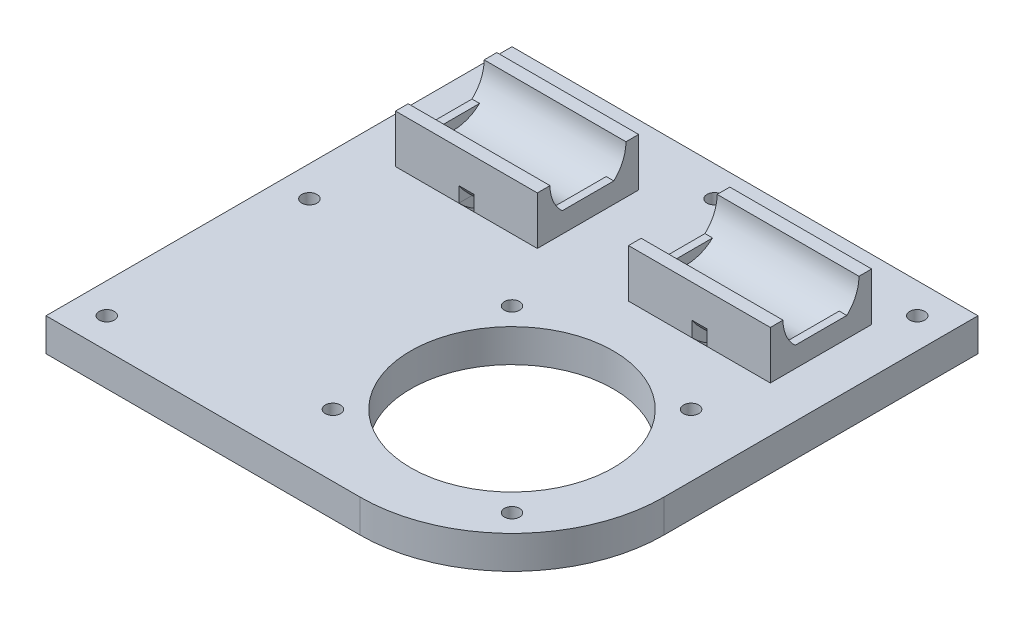
from build123d import *
from build123d.topology import SkipClean

# Parameters (mm, degrees)
EXTRUDE2_DEPTH      = 4
EXTRUDE2_DEPTH_BACK = 2.5
SKETCH7_R           = 20
SKETCH7_R_2         = 1.5
SKETCH8_W           = 28
SKETCH8_H           = 20
EXTRUDE3_DEPTH      = 9.5
EXTRUDE6_DEPTH      = 28
SKETCH15_R          = 7.5
EXTRUDE7_DEPTH      = 25
SKETCH16_W          = 3
SKETCH16_H          = 3
SKETCH8_4_W         = 28
SKETCH8_4_H         = 20
EXTRUDE8_DEPTH      = 9.5
EXTRUDE9_DEPTH      = 28
SKETCH19_R          = 7.5
EXTRUDE10_DEPTH     = 25
SKETCH20_W          = 3
SKETCH20_H          = 3


with BuildPart() as part:
    # Sketch7 → Extrude2 (new, two sides: drawn at the far end of the back side and taken through both)
    with BuildSketch(Plane(origin=(0, 0, 0), x_dir=(1, 0, 0), z_dir=(0, 1, 0)).offset(-EXTRUDE2_DEPTH_BACK)):
        with BuildLine():
            Line((-46, -46), (16, -46))
            ThreePointArc((16, -46), (37.213203436, -37.213203436), (46, -16))
            Line((46, -16), (46, 46))
            Line((46, 46), (-46, 46))
            Line((-46, 46), (-46, -46))
        make_face()
        with Locations((16, -16)):
            Circle(SKETCH7_R, mode=Mode.SUBTRACT)
        with Locations((-1.67766953, 1.67766953)):
            Circle(SKETCH7_R_2, mode=Mode.SUBTRACT)
        with Locations((-40, 40)):
            Circle(SKETCH7_R_2, mode=Mode.SUBTRACT)
        with Locations((-40, -40)):
            Circle(SKETCH7_R_2, mode=Mode.SUBTRACT)
        with Locations((40, 40)):
            Circle(SKETCH7_R_2, mode=Mode.SUBTRACT)
        with Locations((0, 40)):
            Circle(SKETCH7_R_2, mode=Mode.SUBTRACT)
        with Locations((-40, 0)):
            Circle(SKETCH7_R_2, mode=Mode.SUBTRACT)
        with Locations((33.67766953, 1.67766953)):
            Circle(SKETCH7_R_2, mode=Mode.SUBTRACT)
        with Locations((33.67766953, -33.67766953)):
            Circle(SKETCH7_R_2, mode=Mode.SUBTRACT)
        with Locations((-1.67766953, -33.67766953)):
            Circle(SKETCH7_R_2, mode=Mode.SUBTRACT)
    extrude(amount=EXTRUDE2_DEPTH + EXTRUDE2_DEPTH_BACK)


with BuildPart() as body_2:
    # Sketch8 → Extrude3 (new body)
    with BuildSketch(Plane(origin=(0, 4, 0), x_dir=(1, 0, 0), z_dir=(0, 1, 0))):
        with Locations((-23, 24)):
            Rectangle(SKETCH8_W, SKETCH8_H)
    extrude(amount=EXTRUDE3_DEPTH)

    # Sketch10 → Extrude6 (cut)
    with BuildSketch(Plane(origin=(-9, 0, 0), x_dir=(0, 0, -1), z_dir=(1, 0, 0))):
        with BuildLine():
            Line((31.5, 13.5), (24, 13.5))
            Line((24, 13.5), (16.5, 13.5))
            ThreePointArc((16.5, 13.5), (17.126403912, 10.499387259), (18.900980486, 8))
            Line((18.900980486, 8), (29.099019514, 8))
            ThreePointArc((29.099019514, 8), (30.873596088, 10.499387259), (31.5, 13.5))
        make_face()
    extrude(amount=-EXTRUDE6_DEPTH, mode=Mode.SUBTRACT)

    # Sketch15 → Extrude7 (cut)
    with SkipClean():  # the faces are left unmerged after this step: merging them gives an invalid solid
        with BuildSketch(Plane.ZY.offset(35.5)):
            with Locations((-24, 13.5)):
                Circle(SKETCH15_R)
        extrude(amount=-EXTRUDE7_DEPTH, mode=Mode.SUBTRACT)


with BuildPart() as cut_sweep1_tool:
    # Cut-Sweep1: sweep along a path in Sketch17
    with SkipClean():  # the faces are left unmerged after this step: merging them gives an invalid solid
        with BuildLine(Plane(origin=(-23, 0, 0), x_dir=(0, 0, -1), z_dir=(1, 0, 0))) as cut_sweep1_path:
            CenterArc((24, 13.5), 12.806248475, 0, 360)
        # Sketch16 → Cut-Sweep1 (sweep)
        with BuildSketch(Plane.XY.offset(-14)):
            with Locations((-23, 5.5)):
                Rectangle(SKETCH16_W, SKETCH16_H)
        sweep(path=cut_sweep1_path.line)


with BuildPart() as part_1:
    with SkipClean():  # the faces are left unmerged after this step: merging them gives an invalid solid
        add(part.part)

        # Cut-Sweep1: cut by cut_sweep1_tool
        add(cut_sweep1_tool.part, mode=Mode.SUBTRACT)

    # Sketch8_4 → Extrude8 (add)
    with BuildSketch(Plane(origin=(0, 4, 0), x_dir=(1, 0, 0), z_dir=(0, 1, 0))):
        with Locations((23, 24)):
            Rectangle(SKETCH8_4_W, SKETCH8_4_H)
    extrude(amount=EXTRUDE8_DEPTH)

    # Sketch18 → Extrude9 (cut)
    with BuildSketch(Plane(origin=(37, 0, 0), x_dir=(0, 0, -1), z_dir=(1, 0, 0))):
        with BuildLine():
            Line((18.900980486, 8), (29.099019514, 8))
            ThreePointArc((29.099019514, 8), (30.873596088, 10.499387259), (31.5, 13.5))
            Line((31.5, 13.5), (16.5, 13.5))
            ThreePointArc((16.5, 13.5), (17.126403912, 10.499387259), (18.900980486, 8))
        make_face()
    extrude(amount=-EXTRUDE9_DEPTH, mode=Mode.SUBTRACT)

    # Sketch19 → Extrude10 (cut)
    with BuildSketch(Plane(origin=(35.5, 0, 0), x_dir=(0, 0, -1), z_dir=(1, 0, 0))):
        with Locations((24, 13.5)):
            Circle(SKETCH19_R)
    extrude(amount=-EXTRUDE10_DEPTH, mode=Mode.SUBTRACT)

    # Cut-Sweep2: sweep along a path in Sketch21
    with BuildLine(Plane(origin=(23, 0, 0), x_dir=(0, 0, -1), z_dir=(1, 0, 0))) as cut_sweep2_path:
        CenterArc((24, 13.5), 12.806248475, 0, 360)
    # Sketch20 → Cut-Sweep2 (sweep, cut)
    with BuildSketch(Plane.XY.offset(-14)):
        with Locations((23, 5.5)):
            Rectangle(SKETCH20_W, SKETCH20_H)
    sweep(path=cut_sweep2_path.line, mode=Mode.SUBTRACT)


with BuildPart() as body_2_1:
    with SkipClean():  # the faces are left unmerged after this step: merging them gives an invalid solid
        add(body_2.part)

        # Cut-Sweep1: cut by cut_sweep1_tool
        add(cut_sweep1_tool.part, mode=Mode.SUBTRACT)


solid = Compound([part_1.part, body_2_1.part])
